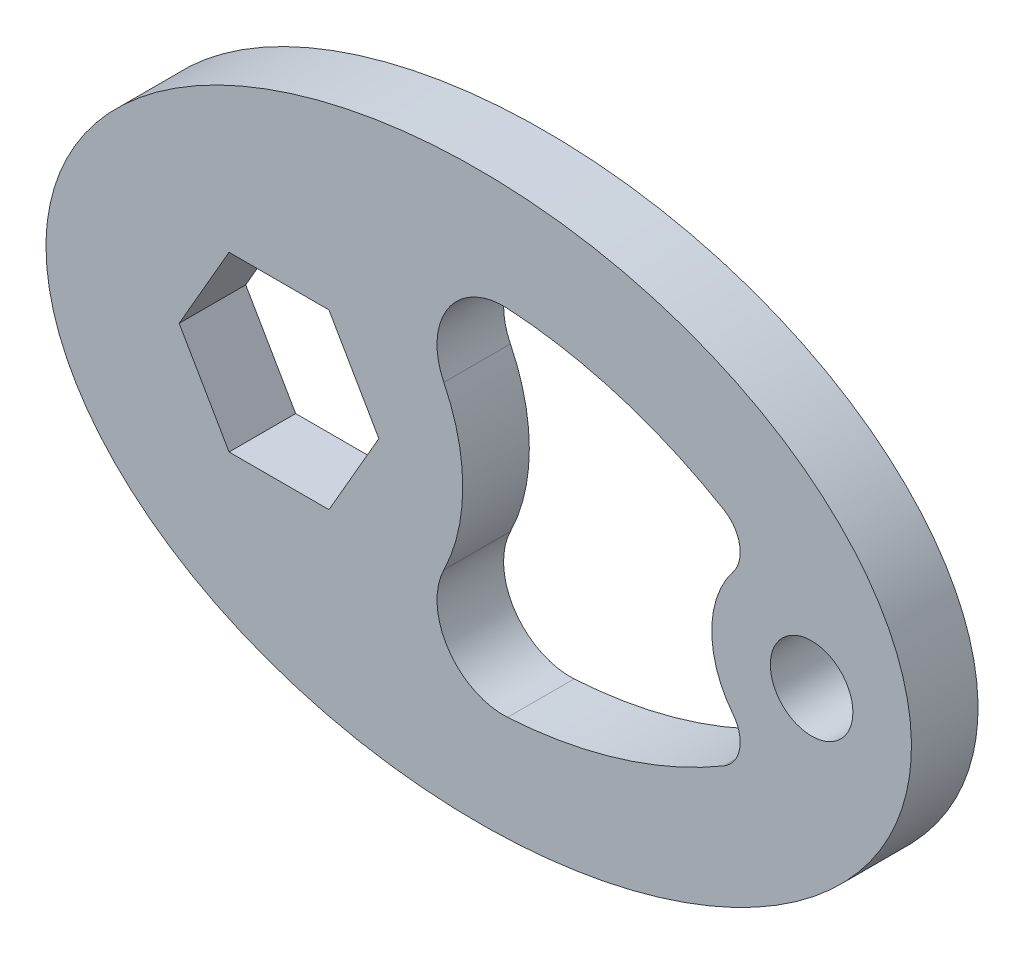
from build123d import *

# Parameters (mm, degrees)
SKETCH1_RX          = 3.25
SKETCH1_RY          = 2.125
SKETCH1_R           = 0.31
BOSS_EXTRUDE1_DEPTH = 0.5


with BuildPart() as part:
    # Sketch1 → Boss-Extrude1 (new body)
    with BuildSketch(Plane.XY):
        with Locations(Location((0, 0), (0, 0, 180))):
            Ellipse(SKETCH1_RX, SKETCH1_RY)
        with Locations((2.5, 0)):
            Circle(SKETCH1_R, mode=Mode.SUBTRACT)
        Polygon((-0.75, 0), (-1.125, 0.649519053), (-1.875, 0.649519053), (-2.25, 0), (-1.875, -0.649519053), (-1.125, -0.649519053), align=None, mode=Mode.SUBTRACT)
        with BuildLine():
            ThreePointArc((1.91030814, 0.463425841), (1.75, 0), (1.91030814, -0.463425841))
            ThreePointArc((1.91030814, -0.463425841), (1.959449463, -0.664041312), (1.840876545, -0.833162274))
            ThreePointArc((1.840876545, -0.833162274), (1.05820698, -1.178058606), (0.216465271, -1.329703007))
            ThreePointArc((0.216465271, -1.329703007), (-0.229872347, -1.107325891), (-0.261988234, -0.609694078))
            ThreePointArc((-0.261988234, -0.609694078), (-0.12, 0), (-0.261988234, 0.609694078))
            ThreePointArc((-0.261988234, 0.609694078), (-0.229872347, 1.107325891), (0.216465271, 1.329703007))
            ThreePointArc((0.216465271, 1.329703007), (1.05820698, 1.178058606), (1.840876545, 0.833162274))
            ThreePointArc((1.840876545, 0.833162274), (1.959449463, 0.664041312), (1.91030814, 0.463425841))
        make_face(mode=Mode.SUBTRACT)
    extrude(amount=BOSS_EXTRUDE1_DEPTH)


solid = part.part
